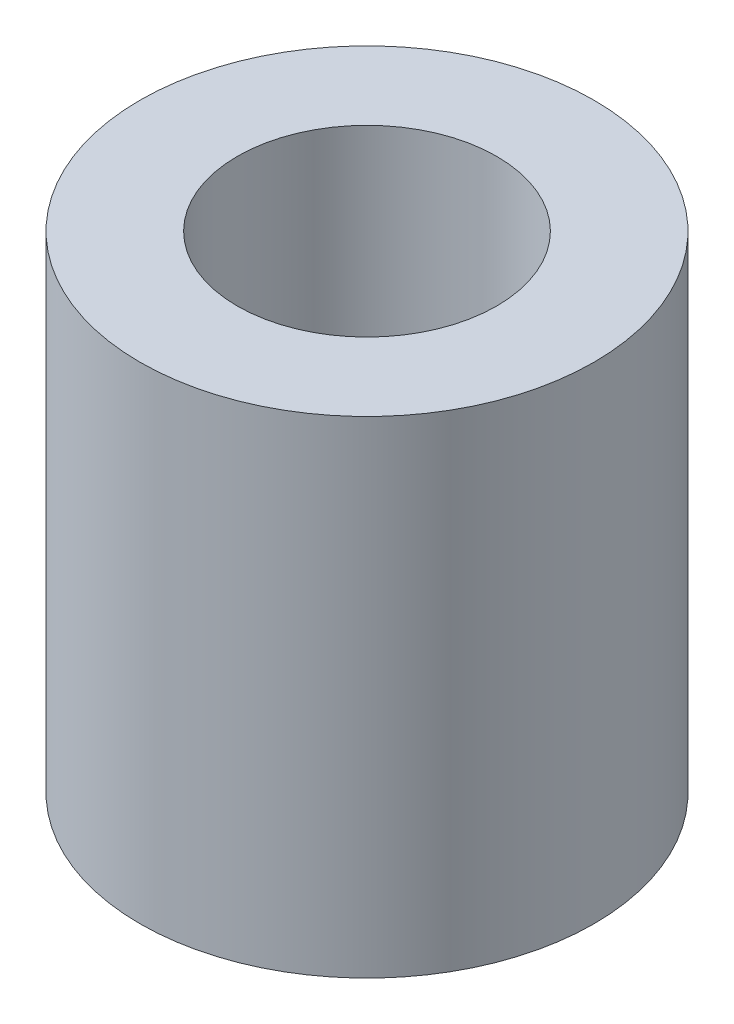
from build123d import *

# Parameters (mm, degrees)
SKETCH1_R           = 4.445
SKETCH1_R_2         = 2.54
BOSS_EXTRUDE1_DEPTH = 9.525


with BuildPart() as part:
    # Sketch1 → Boss-Extrude1 (new body)
    with BuildSketch(Plane(origin=(0, 0, 0), x_dir=(1, 0, 0), z_dir=(0, 1, 0))):
        Circle(SKETCH1_R)
        Circle(SKETCH1_R_2, mode=Mode.SUBTRACT)
    extrude(amount=BOSS_EXTRUDE1_DEPTH)


solid = part.part
